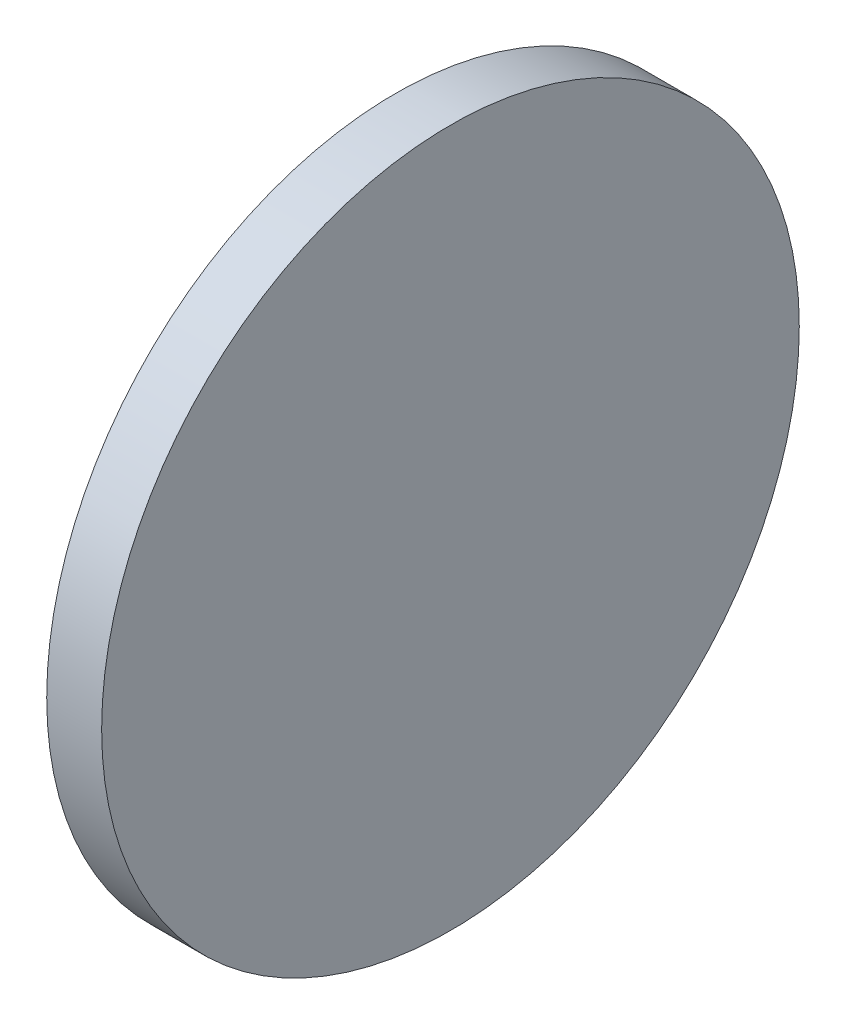
from build123d import *

# Parameters (mm, degrees)
SKETCH_1_W = 2
SKETCH_1_H = 12.7


with BuildPart() as part:
    # 草图1 → 旋转1 (revolve)
    with BuildSketch(Plane.XY, mode=Mode.PRIVATE) as revolve_1_sk:
        with Locations((116.764555476, 71.583554926)):
            Rectangle(SKETCH_1_W, SKETCH_1_H)
    revolve(revolve_1_sk.sketch.rotate(Axis((110.165373228, 65.233554926, 0), (1, 0, 0)), 90), axis=Axis((110.165373228, 65.233554926, 0), (1, 0, 0)))  # turned: the seam where the file's is


solid = part.part
